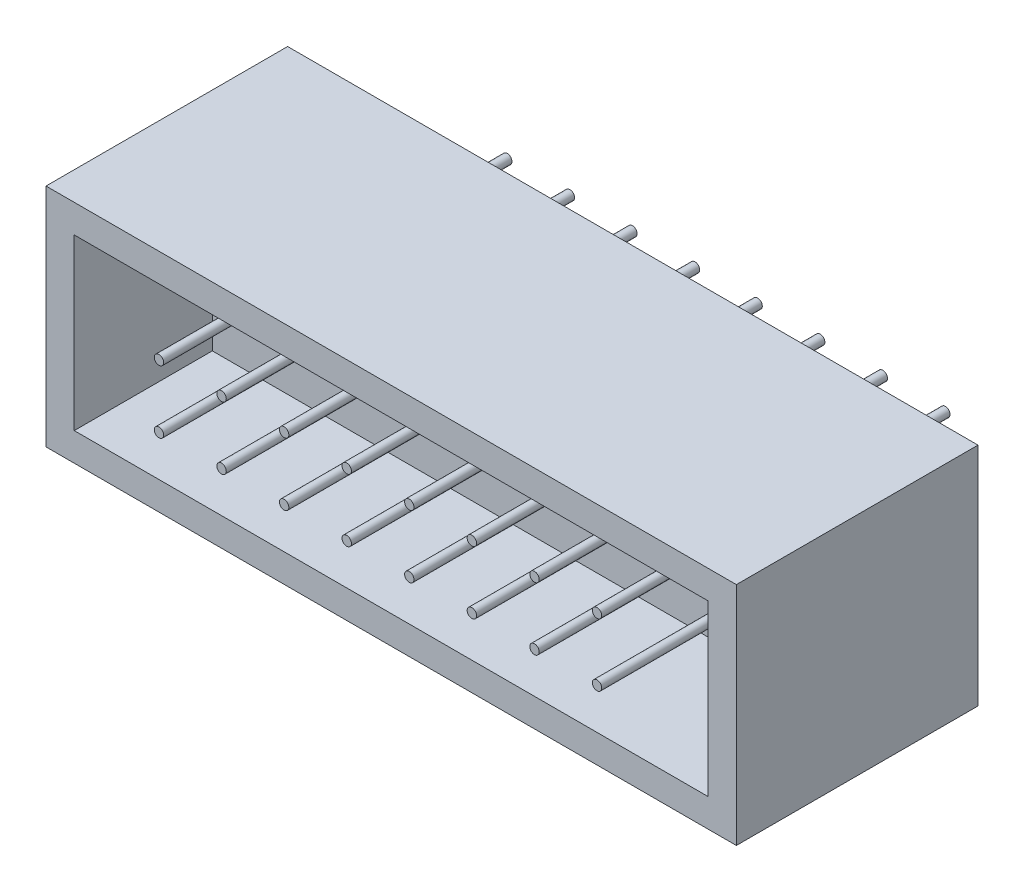
from build123d import *

# Parameters (mm, degrees)
SKETCH1_W           = 27.94
SKETCH1_H           = 9.144
EXTRUDE1_DEPTH      = 9.779
SKETCH2_W           = 25.654
SKETCH2_H           = 6.858
CUT_EXTRUDE1_DEPTH  = 5.588
EXTRUDE3_DEPTH      = 6.096
EXTRUDE3_DEPTH_BACK = 8
SKETCH4_R           = 0.1905


with BuildPart() as part:
    # Sketch1 → Extrude1 (new body)
    with BuildSketch(Plane.XY):
        with Locations((13.97, -4.572)):
            Rectangle(SKETCH1_W, SKETCH1_H)
    extrude(amount=EXTRUDE1_DEPTH)

    # Sketch2 → Cut-Extrude1 (cut)
    with BuildSketch(Plane.XY.offset(9.779)):
        with Locations((13.97, -4.572)):
            Rectangle(SKETCH2_W, SKETCH2_H)
    extrude(amount=-CUT_EXTRUDE1_DEPTH, mode=Mode.SUBTRACT)

    # Sketch4 → Extrude3 (add, two sides: drawn at the far end of the back side and taken through both)
    with BuildSketch(Plane.XY.offset(4.191).offset(-EXTRUDE3_DEPTH_BACK)):
        with Locations((5.08, -5.842)):
            Circle(SKETCH4_R)
        with Locations((7.612742857, -5.842)):
            Circle(SKETCH4_R)
        with Locations((10.145485714, -5.842)):
            Circle(SKETCH4_R)
        with Locations((12.678228571, -5.842)):
            Circle(SKETCH4_R)
        with Locations((15.210971429, -5.842)):
            Circle(SKETCH4_R)
        with Locations((17.743714286, -5.842)):
            Circle(SKETCH4_R)
        with Locations((20.276457143, -5.842)):
            Circle(SKETCH4_R)
        with Locations((22.8092, -5.842)):
            Circle(SKETCH4_R)
        with Locations((5.08, -3.302)):
            Circle(SKETCH4_R)
        with Locations((7.612742857, -3.302)):
            Circle(SKETCH4_R)
        with Locations((10.145485714, -3.302)):
            Circle(SKETCH4_R)
        with Locations((12.678228571, -3.302)):
            Circle(SKETCH4_R)
        with Locations((15.210971429, -3.302)):
            Circle(SKETCH4_R)
        with Locations((17.743714286, -3.302)):
            Circle(SKETCH4_R)
        with Locations((20.276457143, -3.302)):
            Circle(SKETCH4_R)
        with Locations((22.8092, -3.302)):
            Circle(SKETCH4_R)
    extrude(amount=EXTRUDE3_DEPTH + EXTRUDE3_DEPTH_BACK)


solid = part.part
